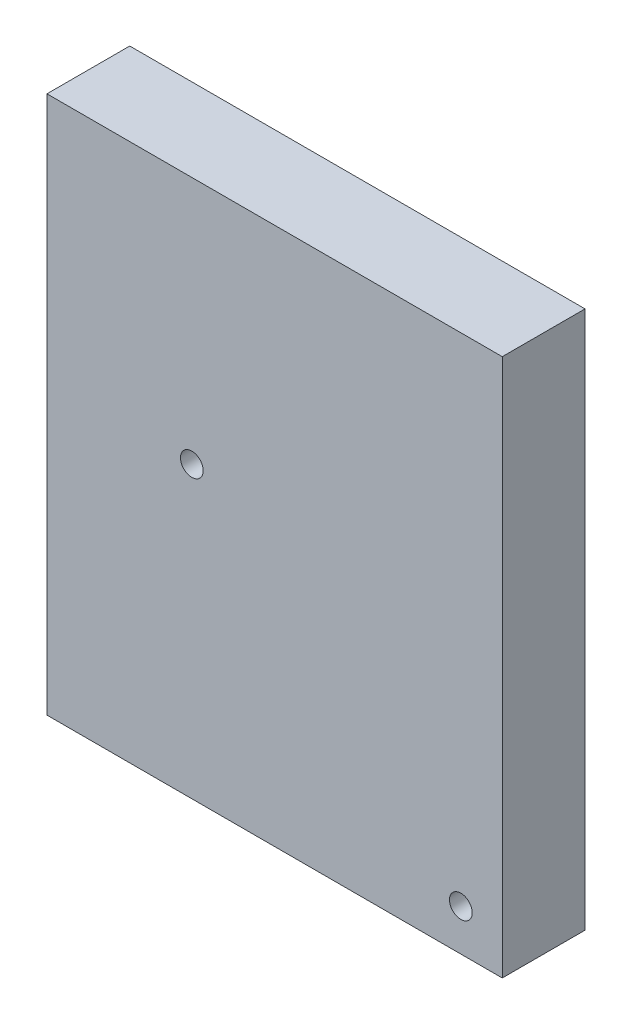
from build123d import *

# Parameters (mm, degrees)
SKETCH1_W           = 55.88
SKETCH1_H           = 66.04
SKETCH1_R           = 1.397
BOSS_EXTRUDE1_DEPTH = 10.16


with BuildPart() as part:
    # Sketch1 → Boss-Extrude1 (new body)
    with BuildSketch(Plane.XY):
        Rectangle(SKETCH1_W, SKETCH1_H)
        with Locations((-10.16, 2.54)):
            Circle(SKETCH1_R, mode=Mode.SUBTRACT)
        with Locations((22.86, -27.94)):
            Circle(SKETCH1_R, mode=Mode.SUBTRACT)
    extrude(amount=BOSS_EXTRUDE1_DEPTH)


solid = part.part
